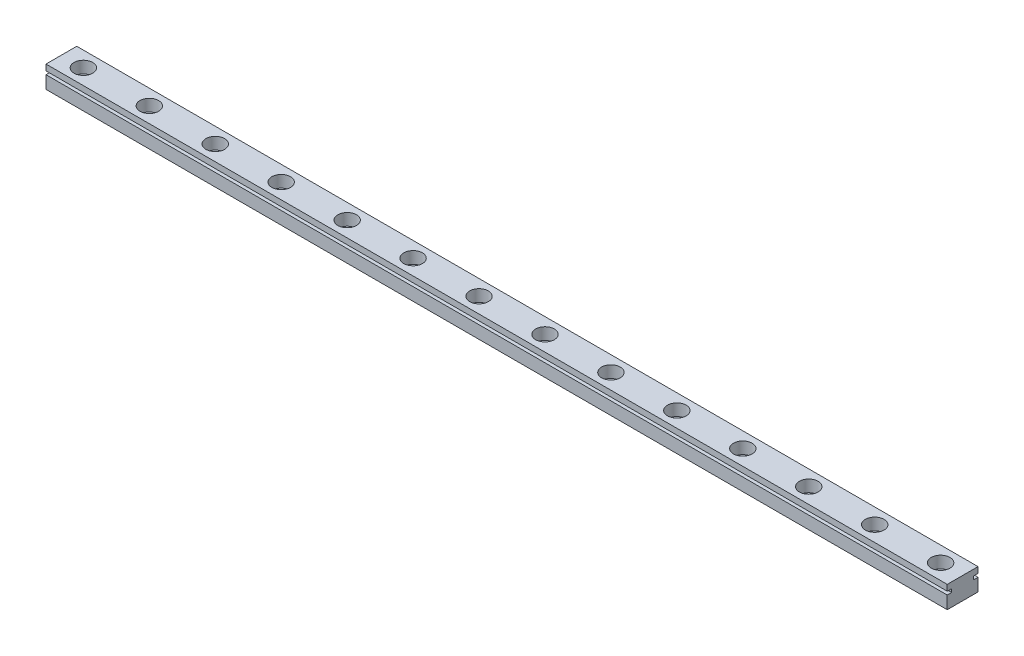
from build123d import *

# Parameters (mm, degrees)
EXTRUDE_1_DEPTH        = 205
SKETCH_3_R             = 1
CUT_EXTRUDE_1_DEPTH    = 25
CUT_EXTRUDE_START      = 2.5
SKETCH_3_3_R           = 2.125
SKETCH_3_3_R_2         = 1
CUT_EXTRUDE_2_DEPTH    = 2.7
PATTERN_LINEAR_1_COUNT = 14
PATTERN_LINEAR_1_PITCH = 15


with BuildPart() as part:
    # 草图2 → 凸台-拉伸1 (new body)
    with BuildSketch(Plane(origin=(0, 0, 0), x_dir=(0, 0, -1), z_dir=(1, 0, 0))):
        Polygon((2.5, 1.15), (3.5, 1.15), (3.5, 2.5), (-3.5, 2.5), (-3.5, 1.15), (-2.5, 1.15), (-2.5, 0.4), (-3.5, 0.4), (-3.5, -2.5), (3.5, -2.5), (3.5, 0.4), (2.5, 0.4), align=None)
    extrude(amount=EXTRUDE_1_DEPTH)

    # 草图3 → 切除-拉伸1 (cut, symmetric)
    with BuildSketch(Plane(origin=(0, 0, 0), x_dir=(1, 0, 0), z_dir=(0, 1, 0))):
        with Locations((5, 0)):
            Circle(SKETCH_3_R)
    cut_extrude_1 = extrude(amount=CUT_EXTRUDE_1_DEPTH, both=True, mode=Mode.SUBTRACT)

    # 草图3<3> → 切除-拉伸2 (cut)
    with BuildSketch(Plane(origin=(0, 0, 0), x_dir=(1, 0, 0), z_dir=(0, 1, 0)).offset(CUT_EXTRUDE_START)):
        with Locations((5, 0)):
            Circle(SKETCH_3_3_R)
        with Locations((5, 0)):
            Circle(SKETCH_3_3_R_2, mode=Mode.SUBTRACT)
    cut_extrude_2 = extrude(amount=-CUT_EXTRUDE_2_DEPTH, mode=Mode.SUBTRACT)

    # 阵列(线性)1: 切除-拉伸1, 切除-拉伸2 ×14
    with Locations(*[(i * PATTERN_LINEAR_1_PITCH, 0, 0) for i in range(1, PATTERN_LINEAR_1_COUNT)]):
        add(cut_extrude_1, mode=Mode.SUBTRACT)
        add(cut_extrude_2, mode=Mode.SUBTRACT)


solid = part.part
